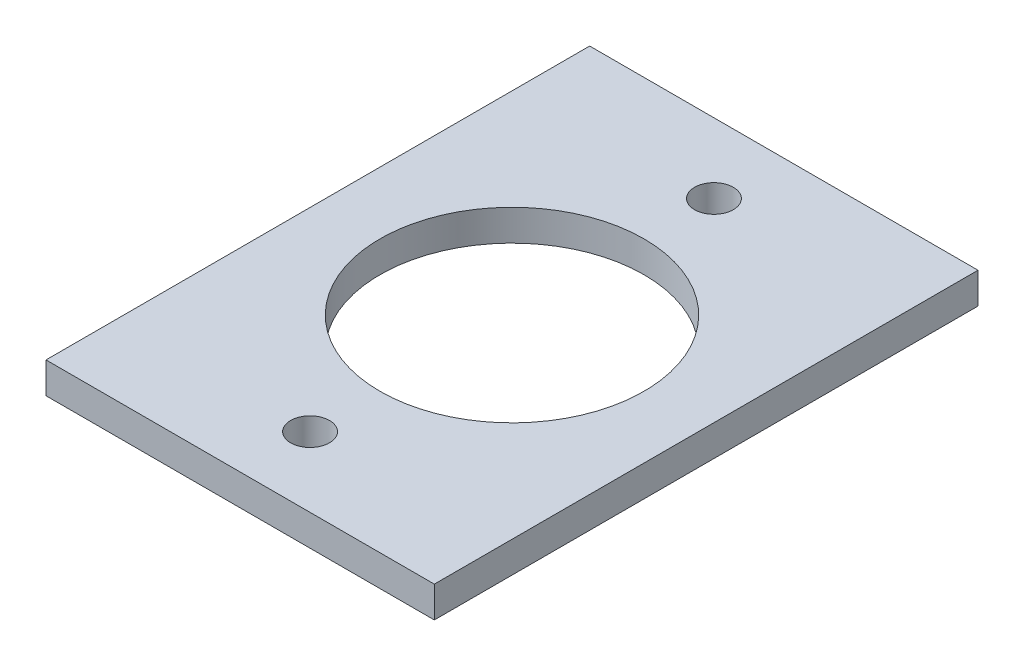
from build123d import *

# Parameters (mm, degrees)
SKETCH_1_W               = 25
SKETCH_1_H               = 35
SKETCH_1_R               = 8.5
EXTRUDE_4_DEPTH          = 2
HOLE_WIZARD_M3_1_D       = 2.5
PATTERN_CIRCULAR_1_COUNT = 2


with BuildPart() as part:
    # 스케치1 → 보스-돌출4 (new body)
    with BuildSketch(Plane(origin=(0, 0, 0), x_dir=(1, 0, 0), z_dir=(0, 1, 0))):
        Rectangle(SKETCH_1_W, SKETCH_1_H)
        Circle(SKETCH_1_R, mode=Mode.SUBTRACT)
    extrude(amount=EXTRUDE_4_DEPTH)

    # M3 탭을 위한 탭 드릴1 (through all)
    with Locations(Plane(origin=(0, 2, 0), x_dir=(1, 0, 0), z_dir=(0, 1, 0))):
        with Locations((0, 13)):
            hole_wizard_m3_1 = Hole(HOLE_WIZARD_M3_1_D / 2)

    # 원형 패턴1: M3 탭을 위한 탭 드릴1 ×2 about axis
    pattern_circular_1_axis = Axis((0, 0, 0), (0, 1, 0))
    for i in range(1, PATTERN_CIRCULAR_1_COUNT):
        add(hole_wizard_m3_1.rotate(pattern_circular_1_axis, i * 360 / PATTERN_CIRCULAR_1_COUNT), mode=Mode.SUBTRACT)


solid = part.part
